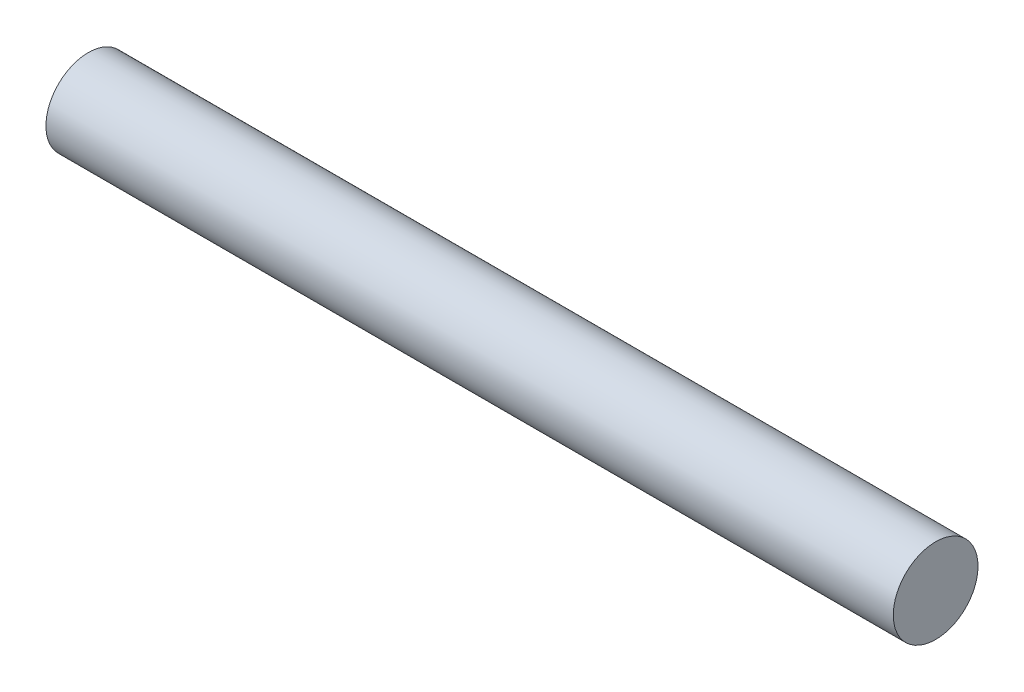
from build123d import *

# Parameters (mm, degrees)
SKETCH1_R           = 15
BOSS_EXTRUDE1_DEPTH = 300


with BuildPart() as part:
    # Sketch1 → Boss-Extrude1 (new body)
    with BuildSketch(Plane(origin=(0, 0, 0), x_dir=(0, 0, -1), z_dir=(1, 0, 0))):
        Circle(SKETCH1_R)
    extrude(amount=BOSS_EXTRUDE1_DEPTH)


solid = part.part
